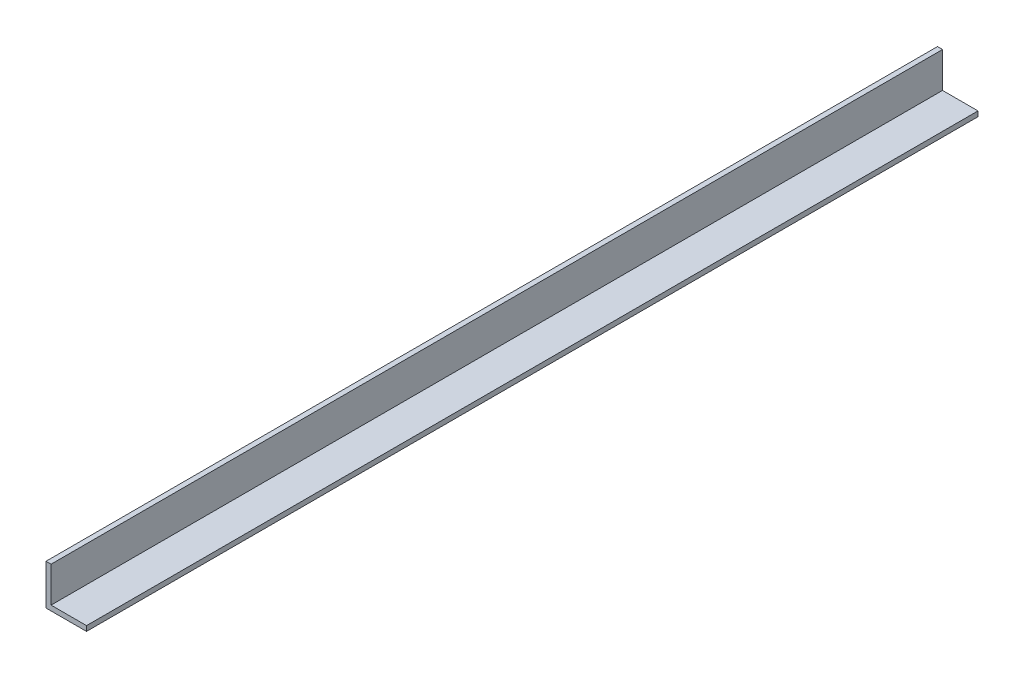
from build123d import *

# Parameters (mm, degrees)
BOSS_EXTRUDE1_DEPTH = 279.4


with BuildPart() as part:
    # Sketch1 → Boss-Extrude1 (new body, symmetric)
    with BuildSketch(Plane.XY):
        Polygon((0, 25.4), (0, 0), (25.4, 0), (25.4, 3.175), (3.175, 3.175), (3.175, 25.4), align=None)
    extrude(amount=BOSS_EXTRUDE1_DEPTH, both=True)


solid = part.part
